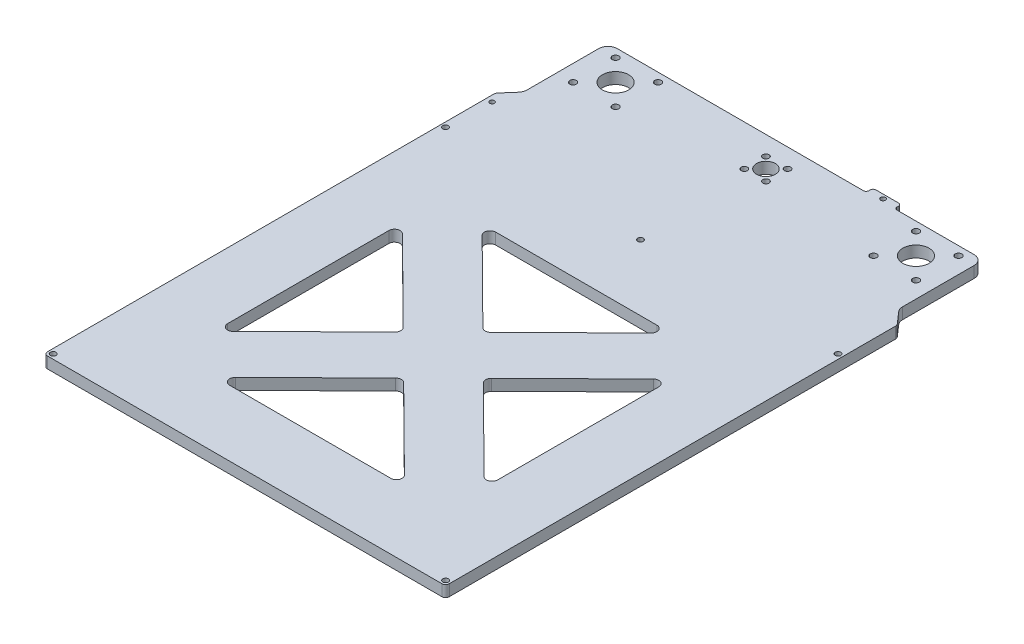
from build123d import *

# Parameters (mm, degrees)
SKETCH_1_R      = 1.25
SKETCH_1_R_2    = 1.5
SKETCH_1_R_3    = 1.65
SKETCH_1_R_4    = 5
SKETCH_1_R_5    = 1.75
SKETCH_1_R_6    = 7
SKETCH_1_R_7    = 1.3
EXTRUDE_1_DEPTH = 6


with BuildPart() as part:
    # Эскиз1 → Бобышка-Вытянуть1 (new body)
    with BuildSketch(Plane(origin=(0, 0, 0), x_dir=(1, 0, 0), z_dir=(0, 1, 0))):
        with BuildLine():
            Line((96.263031015, 98.068479993), (96.263031015, 136.192066055))
            ThreePointArc((96.263031015, 136.192066055), (94.798564921, 139.727599961), (91.263031015, 141.192066055))
            Line((91.263031015, 141.192066055), (50.263031015, 141.192066055))
            ThreePointArc((50.263031015, 141.192066055), (49.202370843, 141.631405883), (48.763031015, 142.692066055))
            Line((48.763031015, 142.692066055), (48.763031015, 143.392066055))
            ThreePointArc((48.763031015, 143.392066055), (48.323691187, 144.452726227), (47.263031015, 144.892066055))
            Line((47.263031015, 144.892066055), (35.263031015, 144.892066055))
            ThreePointArc((35.263031015, 144.892066055), (34.202370843, 144.452726227), (33.763031015, 143.392066055))
            Line((33.763031015, 143.392066055), (33.763031015, 142.692066055))
            ThreePointArc((33.763031015, 142.692066055), (33.323691187, 141.631405883), (32.263031015, 141.192066055))
            Line((32.263031015, 141.192066055), (-98.736968985, 141.192066055))
            ThreePointArc((-98.736968985, 141.192066055), (-102.272502891, 139.727599961), (-103.736968985, 136.192066055))
            Line((-103.736968985, 136.192066055), (-103.736968985, 108.992066055))
            Line((-103.736968985, 108.992066055), (-103.736968985, 102.492066055))
            Line((-103.736968985, 102.492066055), (-103.736968985, 98.068479993))
            ThreePointArc((-103.736968985, 98.068479993), (-104.055758459, 96.311702257), (-104.971476189, 94.778941422))
            Line((-104.971476189, 94.778941422), (-110.214131063, 88.777741336))
            ThreePointArc((-110.214131063, 88.777741336), (-110.580418155, 88.164637002), (-110.707933945, 87.461925907))
            Line((-110.707933945, 87.461925907), (-110.707933945, -150.307933945))
            ThreePointArc((-110.707933945, -150.307933945), (-110.122147507, -151.722147507), (-108.707933945, -152.307933945))
            Line((-108.707933945, -152.307933945), (101.292066055, -152.307933945))
            ThreePointArc((101.292066055, -152.307933945), (102.706279617, -151.722147507), (103.292066055, -150.307933945))
            Line((103.292066055, -150.307933945), (103.292066055, 87.395453829))
            ThreePointArc((103.292066055, 87.395453829), (103.164550265, 88.098164923), (102.798263173, 88.711269257))
            Line((102.798263173, 88.711269257), (97.49753822, 94.778941422))
            ThreePointArc((97.49753822, 94.778941422), (96.581820489, 96.311702258), (96.263031015, 98.068479993))
        make_face()
        with Locations((-107.485559607, 83.246576588)):
            Circle(SKETCH_1_R, mode=Mode.SUBTRACT)
        with Locations((-108.207933945, -149.807933945)):
            Circle(SKETCH_1_R_2, mode=Mode.SUBTRACT)
        with Locations((100.792066055, -149.807933945)):
            Circle(SKETCH_1_R_2, mode=Mode.SUBTRACT)
        with Locations((2.042066055, 131.042066055)):
            Circle(SKETCH_1_R_3, mode=Mode.SUBTRACT)
        with Locations((-9.457933945, 131.042066055)):
            Circle(SKETCH_1_R_3, mode=Mode.SUBTRACT)
        with Locations((-4.430308283, 59.192066055)):
            Circle(SKETCH_1_R_2, mode=Mode.SUBTRACT)
        with Locations((-3.707933945, 125.292066055)):
            Circle(SKETCH_1_R_4, mode=Mode.SUBTRACT)
        with Locations((-72.394225446, 113.878357556)):
            Circle(SKETCH_1_R_5, mode=Mode.SUBTRACT)
        with Locations((-95.021642444, 136.505774554)):
            Circle(SKETCH_1_R_5, mode=Mode.SUBTRACT)
        with Locations((-83.707933945, 125.192066055)):
            Circle(SKETCH_1_R_6, mode=Mode.SUBTRACT)
        with Locations((-72.394225446, 136.505774554)):
            Circle(SKETCH_1_R_5, mode=Mode.SUBTRACT)
        with Locations((-95.021642444, 113.878357556)):
            Circle(SKETCH_1_R_5, mode=Mode.SUBTRACT)
        with Locations((87.605774554, 136.505774554)):
            Circle(SKETCH_1_R_5, mode=Mode.SUBTRACT)
        with Locations((76.292066055, 125.192066055)):
            Circle(SKETCH_1_R_6, mode=Mode.SUBTRACT)
        with Locations((64.978357556, 136.505774554)):
            Circle(SKETCH_1_R_5, mode=Mode.SUBTRACT)
        with Locations((87.605774554, 113.878357556)):
            Circle(SKETCH_1_R_5, mode=Mode.SUBTRACT)
        with Locations((-9.457933945, 119.542066055)):
            Circle(SKETCH_1_R_3, mode=Mode.SUBTRACT)
        with Locations((2.042066055, 119.542066055)):
            Circle(SKETCH_1_R_3, mode=Mode.SUBTRACT)
        with Locations((41.292066055, 142.692066055)):
            Circle(SKETCH_1_R_7, mode=Mode.SUBTRACT)
        with Locations((64.978357556, 113.878357556)):
            Circle(SKETCH_1_R_5, mode=Mode.SUBTRACT)
        with Locations((100.792066055, 59.192066055)):
            Circle(SKETCH_1_R_2, mode=Mode.SUBTRACT)
        with Locations((-108.207933945, 59.192066055)):
            Circle(SKETCH_1_R_2, mode=Mode.SUBTRACT)
        with BuildLine():
            Line((-46.524312559, 24.192066055), (39.306332642, 24.192066055))
            ThreePointArc((39.306332642, 24.192066055), (42.081691212, 22.331094066), (41.413806743, 19.056989261))
            Line((41.413806743, 19.056989261), (-1.577925667, -23.378937563))
            ThreePointArc((-1.577925667, -23.378937563), (-3.688070318, -24.243859581), (-5.796671746, -23.375182104))
            Line((-5.796671746, -23.375182104), (-48.635584538, 19.060744721))
            ThreePointArc((-48.635584538, 19.060744721), (-49.298656086, 22.333564193), (-46.524312559, 24.192066055))
        make_face(mode=Mode.SUBTRACT)
        with BuildLine():
            Line((-75.707933945, -3.543412827), (-75.707933945, -89.374058029))
            ThreePointArc((-75.707933945, -89.374058029), (-73.86499438, -92.141947324), (-70.600459844, -91.509134823))
            Line((-70.600459844, -91.509134823), (-27.200463349, -48.670222031))
            ThreePointArc((-27.200463349, -48.670222031), (-26.307938638, -46.537815787), (-27.19666547, -44.403823902))
            Line((-27.19666547, -44.403823902), (-70.596661966, -1.412091493))
            ThreePointArc((-70.596661966, -1.412091493), (-73.862529992, -0.774494633), (-75.707933945, -3.543412827))
        make_face(mode=Mode.SUBTRACT)
        with BuildLine():
            Line((-46.722200532, -117.307933945), (39.10844467, -117.307933945))
            ThreePointArc((39.10844467, -117.307933945), (41.882788196, -115.449432083), (41.219716649, -112.17661261))
            Line((41.219716649, -112.17661261), (-1.619196144, -69.740685786))
            ThreePointArc((-1.619196144, -69.740685786), (-3.727797572, -68.872008309), (-5.837942223, -69.736930327))
            Line((-5.837942223, -69.736930327), (-48.829674632, -112.172857151))
            ThreePointArc((-48.829674632, -112.172857151), (-49.497559102, -115.446961956), (-46.722200532, -117.307933945))
        make_face(mode=Mode.SUBTRACT)
        with BuildLine():
            Line((68.292066055, -3.741809861), (68.292066055, -89.572455062))
            ThreePointArc((68.292066055, -89.572455062), (66.446662102, -92.341373257), (63.180794076, -91.703776397))
            Line((63.180794076, -91.703776397), (19.78079758, -48.712043988))
            ThreePointArc((19.78079758, -48.712043988), (18.892070748, -46.578052103), (19.784595459, -44.445645859))
            Line((19.784595459, -44.445645859), (63.184591955, -1.606733067))
            ThreePointArc((63.184591955, -1.606733067), (66.44912649, -0.973920566), (68.292066055, -3.741809861))
        make_face(mode=Mode.SUBTRACT)
    extrude(amount=EXTRUDE_1_DEPTH)


solid = part.part
